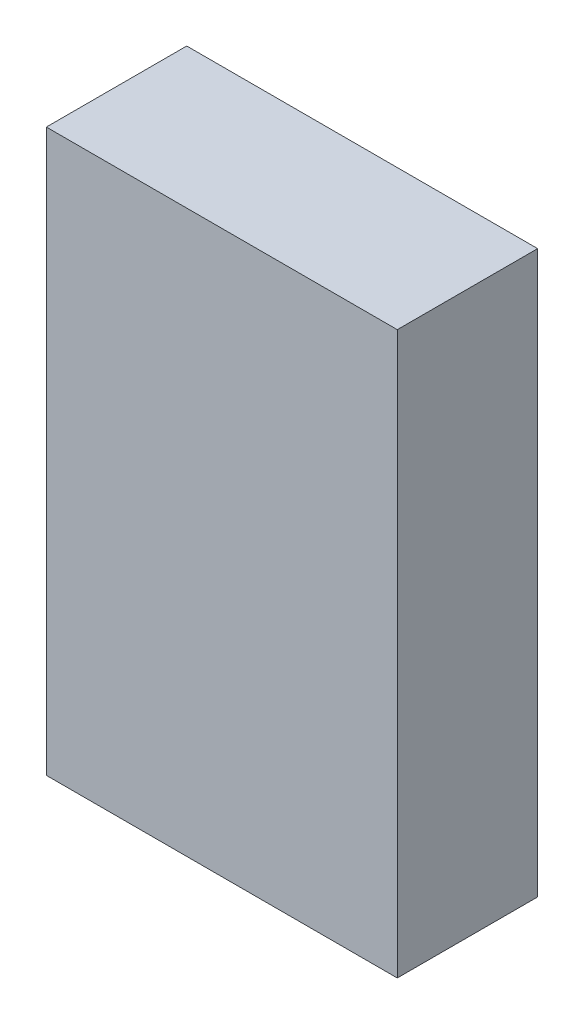
from build123d import *

# Parameters (mm, degrees)
SKETCH1_W           = 15.875
SKETCH1_H           = 25.4
BOSS_EXTRUDE1_DEPTH = 6.35


with BuildPart() as part:
    # Sketch1 → Boss-Extrude1 (new body)
    with BuildSketch(Plane.XY):
        Rectangle(SKETCH1_W, SKETCH1_H)
    extrude(amount=BOSS_EXTRUDE1_DEPTH)


solid = part.part
